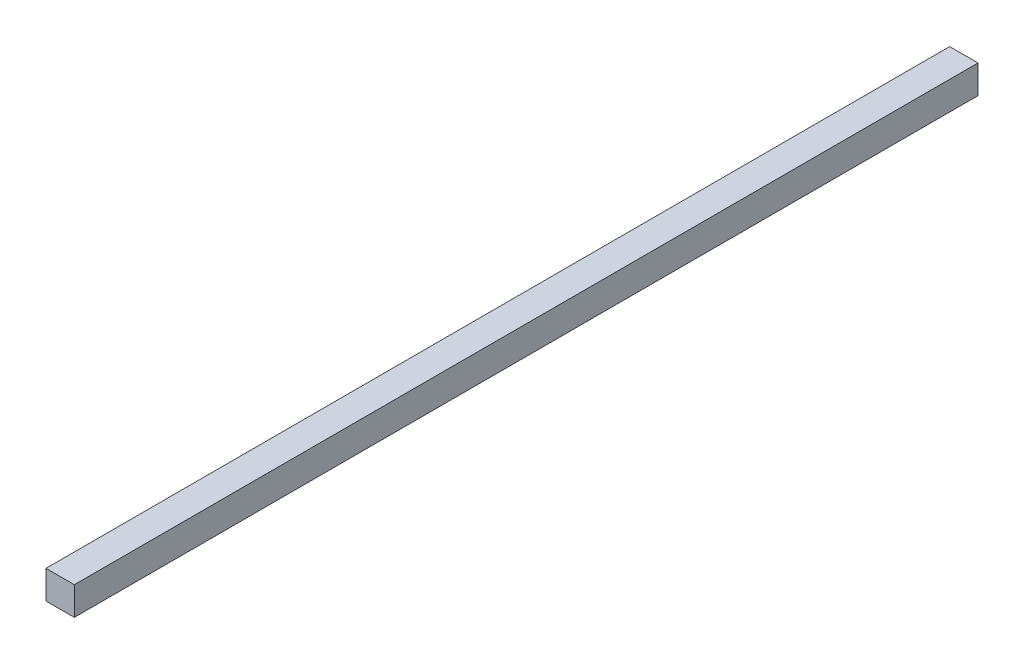
from build123d import *

# Parameters (mm, degrees)
ESQUISSE1_W      = 18
ESQUISSE1_H      = 18
EXTRUSION1_DEPTH = 574


with BuildPart() as part:
    # Esquisse1 → Extrusion1 (new body)
    with BuildSketch(Plane.XY):
        with Locations((9, 9)):
            Rectangle(ESQUISSE1_W, ESQUISSE1_H)
    extrude(amount=-EXTRUSION1_DEPTH)


solid = part.part
